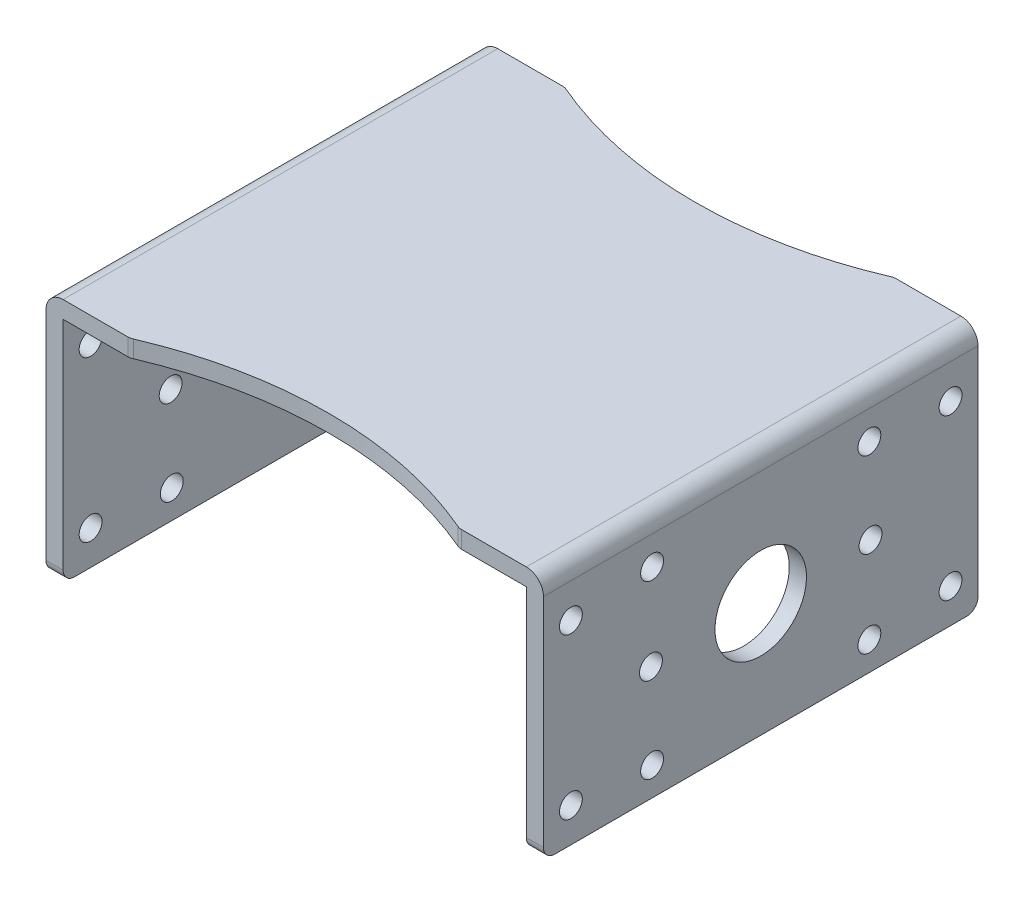
from build123d import *

# Parameters (mm, degrees)
SKETCH_1_W                = 43.5
SKETCH_1_H                = 38
EXTRUDE_1_DEPTH           = 21.5
SKETCH_2_W                = 40.5
SKETCH_2_H                = 20
CUT_EXTRUDE_1_DEPTH       = 39
CUT_EXTRUDE_2_DEPTH       = 22.5
CUT_EXTRUDE_3_DEPTH       = 22.5
HOLE_WIZARD_8_0_8_1_D     = 8
HOLE_WIZARD_8_0_8_1_DEPTH = 1.5
HOLE_WIZARD_2_0_2_1_D     = 2
HOLE_WIZARD_2_0_2_1_DEPTH = 1.5
HOLE_WIZARD_8_0_8_2_D     = 8
HOLE_WIZARD_8_0_8_2_DEPTH = 1.5
HOLE_WIZARD_2_0_2_2_D     = 2
HOLE_WIZARD_2_0_2_2_DEPTH = 1.5
FILLET_1_R                = 1
FILLET_2_R                = 1.5


with BuildPart() as part:
    # 草图1 → 凸台-拉伸1 (new body)
    with BuildSketch(Plane.XZ.offset(20)):
        Rectangle(SKETCH_1_W, SKETCH_1_H)
    extrude(amount=-EXTRUDE_1_DEPTH)

    # 草图2 → 切除-拉伸1 (cut, through all)
    with BuildSketch(Plane.XY.offset(19)):
        with Locations((0, -10)):
            Rectangle(SKETCH_2_W, SKETCH_2_H)
    extrude(amount=-CUT_EXTRUDE_1_DEPTH, mode=Mode.SUBTRACT)

    # 草图3 → 切除-拉伸2 (cut, through all)
    with BuildSketch(Plane(origin=(0, 1.5, 0), x_dir=(-1, 0, 0), z_dir=(0, 1, 0))):
        with BuildLine():
            Line((14.38749457, 19), (-14.38749457, 19))
            ThreePointArc((-14.38749457, 19), (0, 16), (14.38749457, 19))
        make_face()
    extrude(amount=-CUT_EXTRUDE_2_DEPTH, mode=Mode.SUBTRACT)

    # 草图4 → 切除-拉伸3 (cut, through all)
    with BuildSketch(Plane(origin=(0, 1.5, 0), x_dir=(-1, 0, 0), z_dir=(0, 1, 0))):
        with BuildLine():
            Line((-14.38749457, -19), (14.38749457, -19))
            ThreePointArc((14.38749457, -19), (0, -16), (-14.38749457, -19))
        make_face()
    extrude(amount=-CUT_EXTRUDE_3_DEPTH, mode=Mode.SUBTRACT)

    # Ø8.0 (8) 直径孔1
    with Locations(Plane.ZY.offset(-20.25)):
        with Locations((0, -10)):
            Hole(HOLE_WIZARD_8_0_8_1_D / 2, depth=HOLE_WIZARD_8_0_8_1_DEPTH)

    # Ø2.0 (2) 直径孔1
    with Locations(Plane.ZY.offset(-20.25)):
        with Locations((16.6, -3), (16.6, -17), (9.5, -17.5), (9.6, -10), (9.5, -2.5), (-9.5, -2.5), (-16.6, -3), (-16.6, -17), (-9.5, -17.5), (-9.6, -10)):
            Hole(HOLE_WIZARD_2_0_2_1_D / 2, depth=HOLE_WIZARD_2_0_2_1_DEPTH)

    # Ø8.0 (8) 直径孔2
    with Locations(Plane(origin=(-20.25, 0, 0), x_dir=(0, 0, -1), z_dir=(1, 0, 0))):
        with Locations((0, -10)):
            Hole(HOLE_WIZARD_8_0_8_2_D / 2, depth=HOLE_WIZARD_8_0_8_2_DEPTH)

    # Ø2.0 (2) 直径孔2
    with Locations(Plane(origin=(-20.25, 0, 0), x_dir=(0, 0, -1), z_dir=(1, 0, 0))):
        with Locations((-16.6, -3), (-16.6, -17), (-9.5, -17.5), (-9.6, -10), (-9.5, -2.5), (9.5, -2.5), (16.6, -3), (16.6, -17), (9.5, -17.5), (9.6, -10)):
            Hole(HOLE_WIZARD_2_0_2_2_D / 2, depth=HOLE_WIZARD_2_0_2_2_DEPTH)

    # 圆角1
    fillet_1_edges = [part.edges().sort_by_distance(p)[0] for p in [
        (-21, -20, 19),
        (21, -20, -19),
        (-14.38749457, 0.75, 19),
        (14.38749457, 0.75, 19),
        (14.38749457, 0.75, -19),
        (-14.38749457, 0.75, -19),
        (-21, -20, -19),
        (21, -20, 19),
    ]]
    fillet(fillet_1_edges, radius=FILLET_1_R)

    # 圆角2
    fillet_2_edges = [part.edges().sort_by_distance(p)[0] for p in [
        (-21.75, 1.5, 0),
        (21.75, 1.5, 0),
    ]]
    fillet(fillet_2_edges, radius=FILLET_2_R)


solid = part.part
